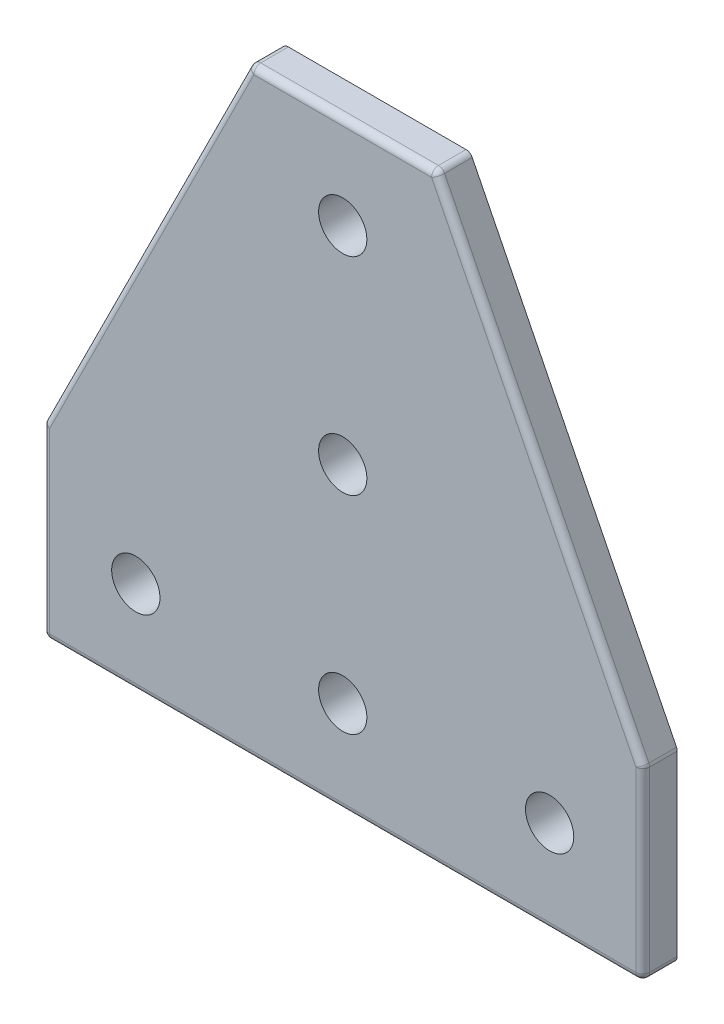
from build123d import *

# Parameters (mm, degrees)
SKETCH1_R           = 3.5
BOSS_EXTRUDE1_DEPTH = 2.5
FILLET1_R           = 1


with BuildPart() as part:
    # Sketch1 → Boss-Extrude1 (new body, symmetric)
    with BuildSketch(Plane.XY):
        Polygon((0, 0), (0, 27), (30, 87), (57, 87), (87, 27), (87, 0), align=None)
        with Locations((13.5, 13.5)):
            Circle(SKETCH1_R, mode=Mode.SUBTRACT)
        with Locations((43.5, 13.5)):
            Circle(SKETCH1_R, mode=Mode.SUBTRACT)
        with Locations((73.5, 13.5)):
            Circle(SKETCH1_R, mode=Mode.SUBTRACT)
        with Locations((43.5, 43.5)):
            Circle(SKETCH1_R, mode=Mode.SUBTRACT)
        with Locations((43.5, 73.5)):
            Circle(SKETCH1_R, mode=Mode.SUBTRACT)
    extrude(amount=BOSS_EXTRUDE1_DEPTH, both=True)

    # Fillet1
    fillet1_edges = [part.edges().sort_by_distance(p)[0] for p in [
        (72, 57, 2.5),
        (0, 0, 0),
        (0, 27, 0),
        (30, 87, 0),
        (57, 87, 0),
        (87, 27, 0),
        (87, 0, 0),
        (43.5, 87, 2.5),
        (15, 57, 2.5),
        (0, 13.5, 2.5),
        (43.5, 0, 2.5),
        (87, 13.5, 2.5),
    ]]
    fillet(fillet1_edges, radius=FILLET1_R)


solid = part.part
